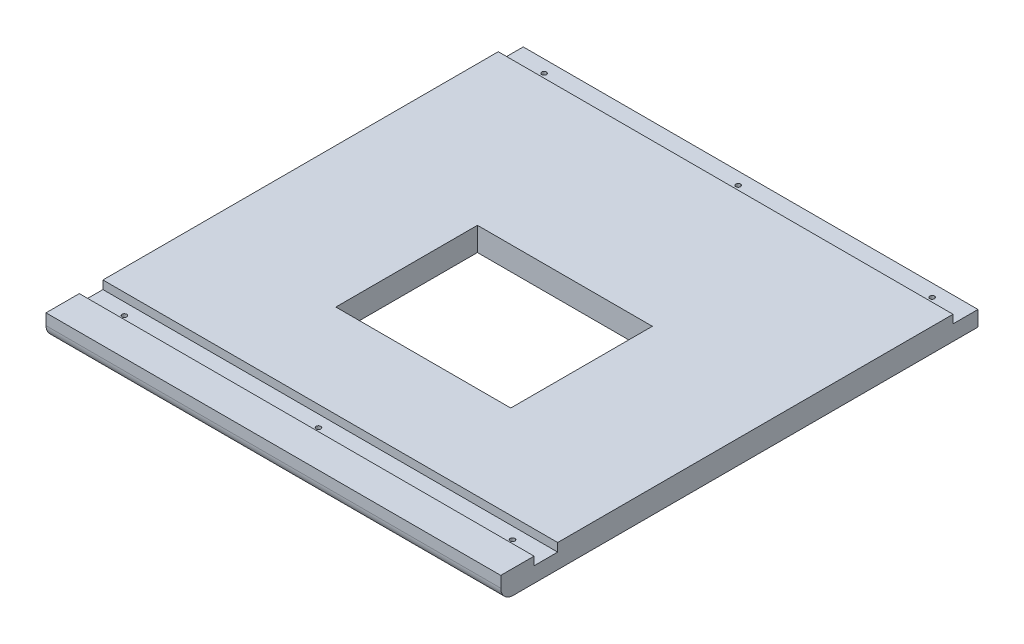
from build123d import *

# Parameters (mm, degrees)
SKETCH1_W           = 346.7
SKETCH1_H           = 376.55000001
BOSS_EXTRUDE1_DEPTH = 18
SKETCH2_W           = 346.7
SKETCH2_H           = 18
CUT_EXTRUDE1_DEPTH  = 6.35
SKETCH3_W           = 133.35
SKETCH3_H           = 107.95
CUT_EXTRUDE3_DEPTH  = 19
FILLET1_R           = 9.525
SKETCH6_W           = 346.7
SKETCH6_H           = 19.05
CUT_EXTRUDE4_DEPTH  = 6.35
SKETCH7_W           = 346.7
SKETCH7_H           = 12.7
CUT_EXTRUDE5_DEPTH  = 19
FILLET2_R           = 9.525
SKETCH8_R           = 1.7859375
CUT_EXTRUDE6_DEPTH  = 12.65


with BuildPart() as part:
    # Sketch1 → Boss-Extrude1 (new body)
    with BuildSketch(Plane(origin=(0, 0, 0), x_dir=(1, 0, 0), z_dir=(0, 1, 0))):
        with Locations((173.35, -188.275000005)):
            Rectangle(SKETCH1_W, SKETCH1_H)
    extrude(amount=BOSS_EXTRUDE1_DEPTH)

    # Sketch2 → Cut-Extrude1 (cut)
    with BuildSketch(Plane(origin=(0, 18, 0), x_dir=(1, 0, 0), z_dir=(0, 1, 0))):
        with Locations((173.35, -329.45000001)):
            Rectangle(SKETCH2_W, SKETCH2_H)
    extrude(amount=-CUT_EXTRUDE1_DEPTH, mode=Mode.SUBTRACT)

    # Sketch3 → Cut-Extrude3 (cut, through all)
    with BuildSketch(Plane(origin=(0, 18, 0), x_dir=(1, 0, 0), z_dir=(0, 1, 0))):
        with Locations((173.35, -195.57500001)):
            Rectangle(SKETCH3_W, SKETCH3_H)
    extrude(amount=-CUT_EXTRUDE3_DEPTH, mode=Mode.SUBTRACT)

    # Fillet1
    fillet1_edges = [part.edges().sort_by_distance(p)[0] for p in [
        (173.35, 0, 376.55000001),
    ]]
    fillet(fillet1_edges, radius=FILLET1_R)

    # Sketch6 → Cut-Extrude4 (cut)
    with BuildSketch(Plane(origin=(0, 18, 0), x_dir=(1, 0, 0), z_dir=(0, 1, 0))):
        with Locations((173.35, -9.525)):
            Rectangle(SKETCH6_W, SKETCH6_H)
    extrude(amount=-CUT_EXTRUDE4_DEPTH, mode=Mode.SUBTRACT)

    # Sketch7 → Cut-Extrude5 (cut, through all)
    with BuildSketch(Plane(origin=(0, 18, 0), x_dir=(1, 0, 0), z_dir=(0, 1, 0))):
        with Locations((173.35, -370.20000001)):
            Rectangle(SKETCH7_W, SKETCH7_H)
    extrude(amount=-CUT_EXTRUDE5_DEPTH, mode=Mode.SUBTRACT)

    # Fillet2
    fillet2_edges = [part.edges().sort_by_distance(p)[0] for p in [
        (173.35, 0, 363.85000001),
    ]]
    fillet(fillet2_edges, radius=FILLET2_R)

    # Sketch8 → Cut-Extrude6 (cut, through all)
    with BuildSketch(Plane(origin=(0, 11.65, 0), x_dir=(1, 0, 0), z_dir=(0, 1, 0))):
        with Locations((173.35, -9.525)):
            Circle(SKETCH8_R)
        with Locations((173.35, -329.45000001)):
            Circle(SKETCH8_R)
        with Locations((25.4, -329.45000001)):
            Circle(SKETCH8_R)
        with Locations((321.3, -329.45000001)):
            Circle(SKETCH8_R)
        with Locations((321.3, -9.525)):
            Circle(SKETCH8_R)
        with Locations((25.4, -9.525)):
            Circle(SKETCH8_R)
    extrude(amount=-CUT_EXTRUDE6_DEPTH, mode=Mode.SUBTRACT)


solid = part.part
